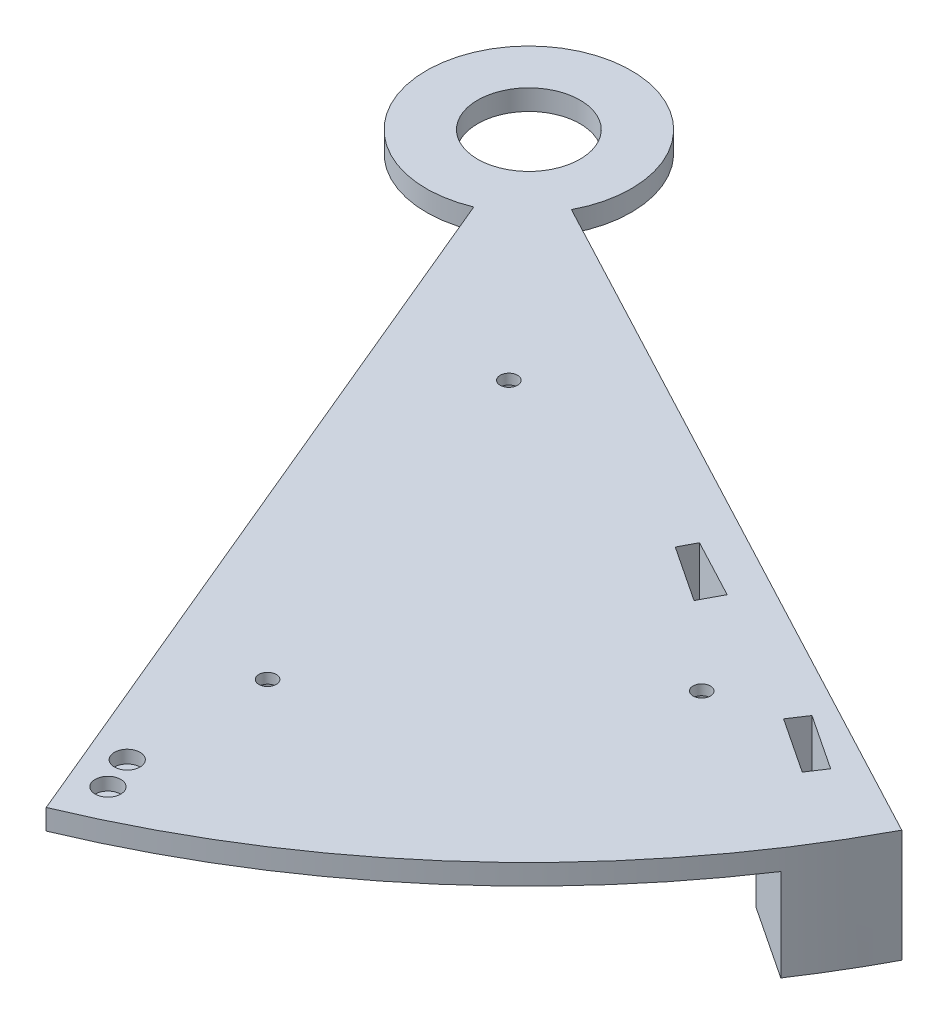
from build123d import *

# Parameters (mm, degrees)
EXTRUDE_2_DEPTH     = 4
SKETCH_2_R          = 2.5
CUT_EXTRUDE_1_DEPTH = 2.5
SKETCH_3_R          = 0.75
CUT_EXTRUDE_2_DEPTH = 5
SKETCH_4_R          = 10
CUT_EXTRUDE_3_DEPTH = 5
EXTRUDE_5_DEPTH     = 18
SKETCH_7_R          = 1.7
CUT_EXTRUDE_4_DEPTH = 10
SKETCH_8_R          = 3
CUT_EXTRUDE_5_DEPTH = 2
CUT_EXTRUDE_6_DEPTH = 23
CUT_EXTRUDE_7_DEPTH = 6
CUT_EXTRUDE_8_DEPTH = 6
CUT_EXTRUDE_9_DEPTH = 23


with BuildPart() as part:
    # Sketch 1 → Extrude 2 (new body)
    with BuildSketch(Plane(origin=(0, 0, 0), x_dir=(1, 0, 0), z_dir=(0, 1, 0))):
        with BuildLine():
            Line((67.500002573, -161.729132047), (7.703281321, -18.456962288))
            ThreePointArc((7.703281321, -18.456962288), (-13.478048898, 14.776406799), (17.672702948, -9.363523402))
            Line((17.672702948, -9.363523402), (154.857059584, -82.047873812))
            ThreePointArc((154.857059584, -82.047873812), (118.101403468, -129.478264581), (67.500002573, -161.729132047))
        make_face()
    extrude(amount=EXTRUDE_2_DEPTH)

    # Sketch 2 → Cut-Extrude 1 (cut)
    with BuildSketch(Plane(origin=(0, 4, 0), x_dir=(1, 0, 0), z_dir=(0, 1, 0))):
        with Locations((70.025207674, -152.204211145)):
            Circle(SKETCH_2_R)
        with Locations((67.327175776, -145.739984225)):
            Circle(SKETCH_2_R)
    extrude(amount=-CUT_EXTRUDE_1_DEPTH, mode=Mode.SUBTRACT)

    # Sketch 3 → Cut-Extrude 2 (cut, through all)
    with BuildSketch(Plane(origin=(0, 4, 0), x_dir=(1, 0, 0), z_dir=(0, 1, 0))):
        with Locations((70.025207674, -152.204211145)):
            Circle(SKETCH_3_R)
        with Locations((67.327175776, -145.739984225)):
            Circle(SKETCH_3_R)
    extrude(amount=-CUT_EXTRUDE_2_DEPTH, mode=Mode.SUBTRACT)

    # Sketch 4 → Cut-Extrude 3 (cut, through all)
    with BuildSketch(Plane(origin=(0, 4, 0), x_dir=(1, 0, 0), z_dir=(0, 1, 0))):
        Circle(SKETCH_4_R)
    extrude(amount=-CUT_EXTRUDE_3_DEPTH, mode=Mode.SUBTRACT)

    # Sketch 6 → Extrude 5 (add)
    with BuildSketch(Plane.XZ):
        with BuildLine():
            ThreePointArc((16.66785969, 11.053617207), (17.191063517, 10.220926336), (17.672702948, 9.363523402))
            Line((17.672702948, 9.363523402), (154.857059584, 82.047873812))
            ThreePointArc((154.857059584, 82.047873812), (150.636694066, 89.560867018), (146.05212053, 96.857320781))
            Line((146.05212053, 96.857320781), (16.66785969, 11.053617207))
        make_face()
    extrude(amount=EXTRUDE_5_DEPTH)

    # Sketch 7 → Cut-Extrude 4 (cut)
    with BuildSketch(Plane.XZ):
        with Locations((40.434146694, 44.329220398)):
            Circle(SKETCH_7_R)
        with Locations((111.793635371, 78.04603187)):
            Circle(SKETCH_7_R)
        with Locations((67.464414972, 118.480178564)):
            Circle(SKETCH_7_R)
    extrude(amount=-CUT_EXTRUDE_4_DEPTH, mode=Mode.SUBTRACT)

    # Sketch 8 → Cut-Extrude 5 (cut)
    with BuildSketch(Plane.XZ):
        with Locations((111.793635371, 78.04603187)):
            Circle(SKETCH_8_R)
        with Locations((40.434146694, 44.329220398)):
            Circle(SKETCH_8_R)
        with Locations((67.464414972, 118.480178564)):
            Circle(SKETCH_8_R)
    extrude(amount=-CUT_EXTRUDE_5_DEPTH, mode=Mode.SUBTRACT)

    # Sketch 9 → Cut-Extrude 6 (cut, through all)
    with BuildSketch(Plane.XZ.offset(18)):
        Polygon((95.759242986, 63.504615216), (84.872522382, 56.284873482), (86.511138977, 53.192150466), (97.998395894, 59.278440678), (96.359779298, 62.371163694), align=None)
    extrude(amount=-CUT_EXTRUDE_6_DEPTH, mode=Mode.SUBTRACT)

    # Sketch 9_3 → Cut-Extrude 7 (cut)
    with BuildSketch(Plane.XZ.offset(18)):
        Polygon((97.998395894, 59.278440678), (86.511138977, 53.192150466), (89.554284083, 47.448522008), (101.041540999, 53.53481222), align=None)
    extrude(amount=-CUT_EXTRUDE_7_DEPTH, mode=Mode.SUBTRACT)

    # Sketch 10 → Cut-Extrude 8 (cut)
    with BuildSketch(Plane.XZ.offset(18)):
        Polygon((131.739790556, 87.365819183), (120.905681758, 80.180967998), (124.49810735, 74.763913599), (135.332216149, 81.948764784), align=None)
    extrude(amount=-CUT_EXTRUDE_8_DEPTH, mode=Mode.SUBTRACT)

    # Sketch 10_3 → Cut-Extrude 9 (cut, through all)
    with BuildSketch(Plane.XZ.offset(18)):
        Polygon((124.49810735, 74.763913599), (126.708830792, 71.430341661), (137.54293959, 78.615192846), (135.332216149, 81.948764784), align=None)
    extrude(amount=-CUT_EXTRUDE_9_DEPTH, mode=Mode.SUBTRACT)


solid = part.part
